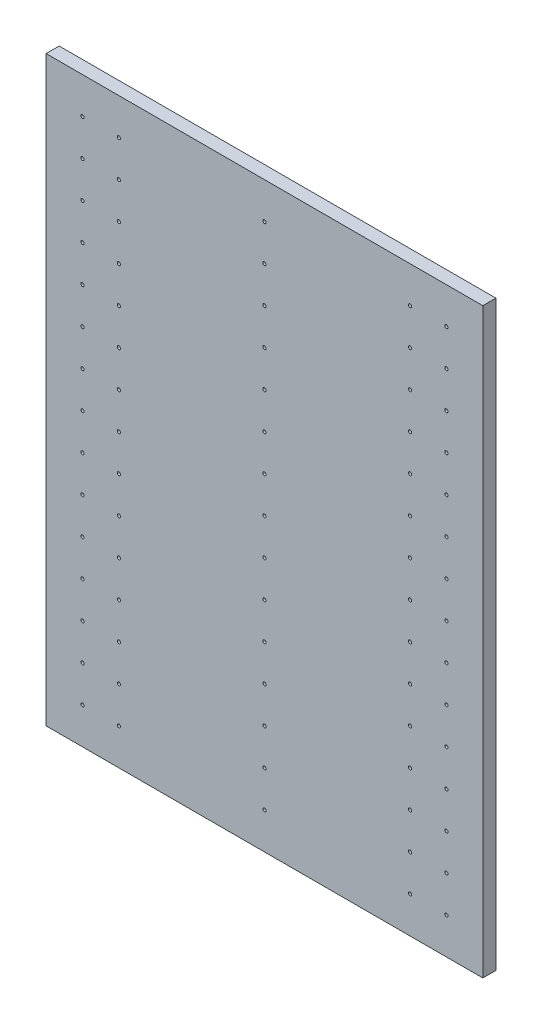
from build123d import *

# Parameters (mm, degrees)
SKETCH_1_W          = 600
SKETCH_1_H          = 800
EXTRUDE_1_DEPTH     = 18
SKETCH_2_R          = 2.25
CUT_EXTRUDE_1_DEPTH = 9


with BuildPart() as part:
    # Эскиз1 → Бобышка-Вытянуть1 (new body)
    with BuildSketch(Plane.XY):
        with Locations((300, 400)):
            Rectangle(SKETCH_1_W, SKETCH_1_H)
    extrude(amount=EXTRUDE_1_DEPTH)

    # Эскиз2 → Вырез-Вытянуть1 (cut)
    with BuildSketch(Plane.XY.offset(18)):
        with Locations((550, 50)):
            Circle(SKETCH_2_R)
        with Locations((300, 50)):
            Circle(SKETCH_2_R)
        with Locations((500, 50)):
            Circle(SKETCH_2_R)
        with Locations((100, 50)):
            Circle(SKETCH_2_R)
        with Locations((50, 50)):
            Circle(SKETCH_2_R)
        with Locations((550, 100)):
            Circle(SKETCH_2_R)
        with Locations((300, 100)):
            Circle(SKETCH_2_R)
        with Locations((500, 100)):
            Circle(SKETCH_2_R)
        with Locations((100, 100)):
            Circle(SKETCH_2_R)
        with Locations((50, 100)):
            Circle(SKETCH_2_R)
        with Locations((550, 150)):
            Circle(SKETCH_2_R)
        with Locations((300, 150)):
            Circle(SKETCH_2_R)
        with Locations((500, 150)):
            Circle(SKETCH_2_R)
        with Locations((100, 150)):
            Circle(SKETCH_2_R)
        with Locations((50, 150)):
            Circle(SKETCH_2_R)
        with Locations((550, 200)):
            Circle(SKETCH_2_R)
        with Locations((300, 200)):
            Circle(SKETCH_2_R)
        with Locations((500, 200)):
            Circle(SKETCH_2_R)
        with Locations((100, 200)):
            Circle(SKETCH_2_R)
        with Locations((50, 200)):
            Circle(SKETCH_2_R)
        with Locations((550, 250)):
            Circle(SKETCH_2_R)
        with Locations((300, 250)):
            Circle(SKETCH_2_R)
        with Locations((500, 250)):
            Circle(SKETCH_2_R)
        with Locations((100, 250)):
            Circle(SKETCH_2_R)
        with Locations((50, 250)):
            Circle(SKETCH_2_R)
        with Locations((550, 300)):
            Circle(SKETCH_2_R)
        with Locations((300, 300)):
            Circle(SKETCH_2_R)
        with Locations((500, 300)):
            Circle(SKETCH_2_R)
        with Locations((100, 300)):
            Circle(SKETCH_2_R)
        with Locations((50, 300)):
            Circle(SKETCH_2_R)
        with Locations((550, 350)):
            Circle(SKETCH_2_R)
        with Locations((300, 350)):
            Circle(SKETCH_2_R)
        with Locations((500, 350)):
            Circle(SKETCH_2_R)
        with Locations((100, 350)):
            Circle(SKETCH_2_R)
        with Locations((50, 350)):
            Circle(SKETCH_2_R)
        with Locations((550, 400)):
            Circle(SKETCH_2_R)
        with Locations((300, 400)):
            Circle(SKETCH_2_R)
        with Locations((500, 400)):
            Circle(SKETCH_2_R)
        with Locations((100, 400)):
            Circle(SKETCH_2_R)
        with Locations((50, 400)):
            Circle(SKETCH_2_R)
        with Locations((550, 450)):
            Circle(SKETCH_2_R)
        with Locations((300, 450)):
            Circle(SKETCH_2_R)
        with Locations((500, 450)):
            Circle(SKETCH_2_R)
        with Locations((100, 450)):
            Circle(SKETCH_2_R)
        with Locations((50, 450)):
            Circle(SKETCH_2_R)
        with Locations((550, 500)):
            Circle(SKETCH_2_R)
        with Locations((300, 500)):
            Circle(SKETCH_2_R)
        with Locations((500, 500)):
            Circle(SKETCH_2_R)
        with Locations((100, 500)):
            Circle(SKETCH_2_R)
        with Locations((50, 500)):
            Circle(SKETCH_2_R)
        with Locations((550, 550)):
            Circle(SKETCH_2_R)
        with Locations((300, 550)):
            Circle(SKETCH_2_R)
        with Locations((500, 550)):
            Circle(SKETCH_2_R)
        with Locations((100, 550)):
            Circle(SKETCH_2_R)
        with Locations((50, 550)):
            Circle(SKETCH_2_R)
        with Locations((550, 600)):
            Circle(SKETCH_2_R)
        with Locations((300, 600)):
            Circle(SKETCH_2_R)
        with Locations((500, 600)):
            Circle(SKETCH_2_R)
        with Locations((100, 600)):
            Circle(SKETCH_2_R)
        with Locations((50, 600)):
            Circle(SKETCH_2_R)
        with Locations((550, 650)):
            Circle(SKETCH_2_R)
        with Locations((300, 650)):
            Circle(SKETCH_2_R)
        with Locations((500, 650)):
            Circle(SKETCH_2_R)
        with Locations((100, 650)):
            Circle(SKETCH_2_R)
        with Locations((50, 650)):
            Circle(SKETCH_2_R)
        with Locations((550, 700)):
            Circle(SKETCH_2_R)
        with Locations((300, 700)):
            Circle(SKETCH_2_R)
        with Locations((500, 700)):
            Circle(SKETCH_2_R)
        with Locations((100, 700)):
            Circle(SKETCH_2_R)
        with Locations((50, 700)):
            Circle(SKETCH_2_R)
        with Locations((550, 750)):
            Circle(SKETCH_2_R)
        with Locations((300, 750)):
            Circle(SKETCH_2_R)
        with Locations((500, 750)):
            Circle(SKETCH_2_R)
        with Locations((100, 750)):
            Circle(SKETCH_2_R)
        with Locations((50, 750)):
            Circle(SKETCH_2_R)
    extrude(amount=-CUT_EXTRUDE_1_DEPTH, mode=Mode.SUBTRACT)


solid = part.part
